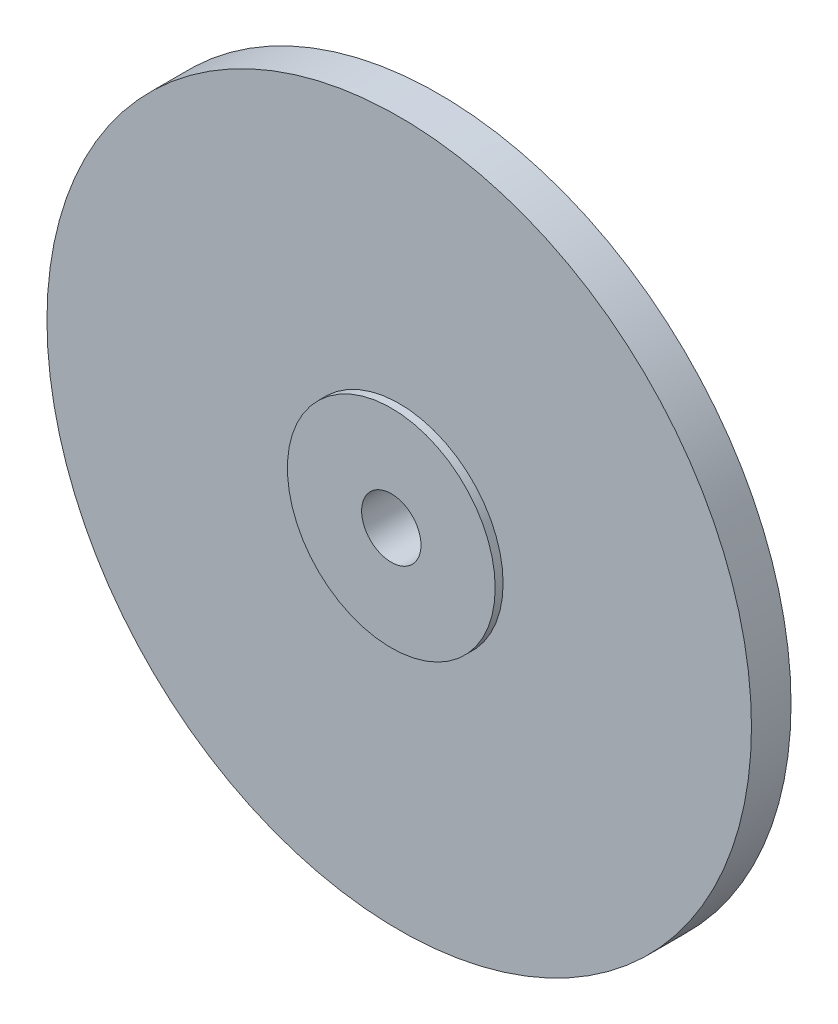
from build123d import *

# Parameters (mm, degrees)
SKETCH_1_R          = 17.8
EXTRUDE_1_DEPTH     = 2
SKETCH_2_R          = 7.85
EXTRUDE_2_DEPTH     = 0.8
DRAFT_1_ANGLE       = 1
SKETCH_38_R         = 4.8
EXTRUDE_3_DEPTH     = 1.9
SKETCH_39_R         = 5.25
EXTRUDE_4_DEPTH     = 0.4
SKETCH_40_R         = 1.5
CUT_EXTRUDE_1_DEPTH = 10.4


with BuildPart() as part:
    # ｽｹｯﾁ1 → ﾎﾞｽ - 押し出し1 (new body)
    with BuildSketch(Plane.XY):
        Circle(SKETCH_1_R)
    extrude(amount=EXTRUDE_1_DEPTH)

    # ｽｹｯﾁ2 → ﾎﾞｽ - 押し出し2 (add)
    with BuildSketch(Plane(origin=(0, 0, 0), x_dir=(-1, 0, 0), z_dir=(0, 0, -1))):
        Circle(SKETCH_2_R)
    extrude(amount=EXTRUDE_2_DEPTH)

    # 抜き勾配1
    draft_1_faces = [part.faces().sort_by_distance(p)[0] for p in [
        (7.85, 0, -0.4),
    ]]
    draft(draft_1_faces, Plane(origin=(0, 0, -0.8), x_dir=(-1, 0, 0), z_dir=(0, 0, -1)), DRAFT_1_ANGLE)

    # ｽｹｯﾁ38 → ﾎﾞｽ - 押し出し3 (add)
    with BuildSketch(Plane(origin=(0, 0, -0.8), x_dir=(-1, 0, 0), z_dir=(0, 0, -1))):
        Circle(SKETCH_38_R)
    extrude(amount=EXTRUDE_3_DEPTH)

    # ｽｹｯﾁ39 → ﾎﾞｽ - 押し出し4 (add)
    with BuildSketch(Plane.XY.offset(2)):
        Circle(SKETCH_39_R)
    extrude(amount=EXTRUDE_4_DEPTH)

    # ｽｹｯﾁ40 → ｶｯﾄ - 押し出し1 (cut)
    with BuildSketch(Plane.XY.offset(2.4)):
        Circle(SKETCH_40_R)
    extrude(amount=-CUT_EXTRUDE_1_DEPTH, mode=Mode.SUBTRACT)


solid = part.part
